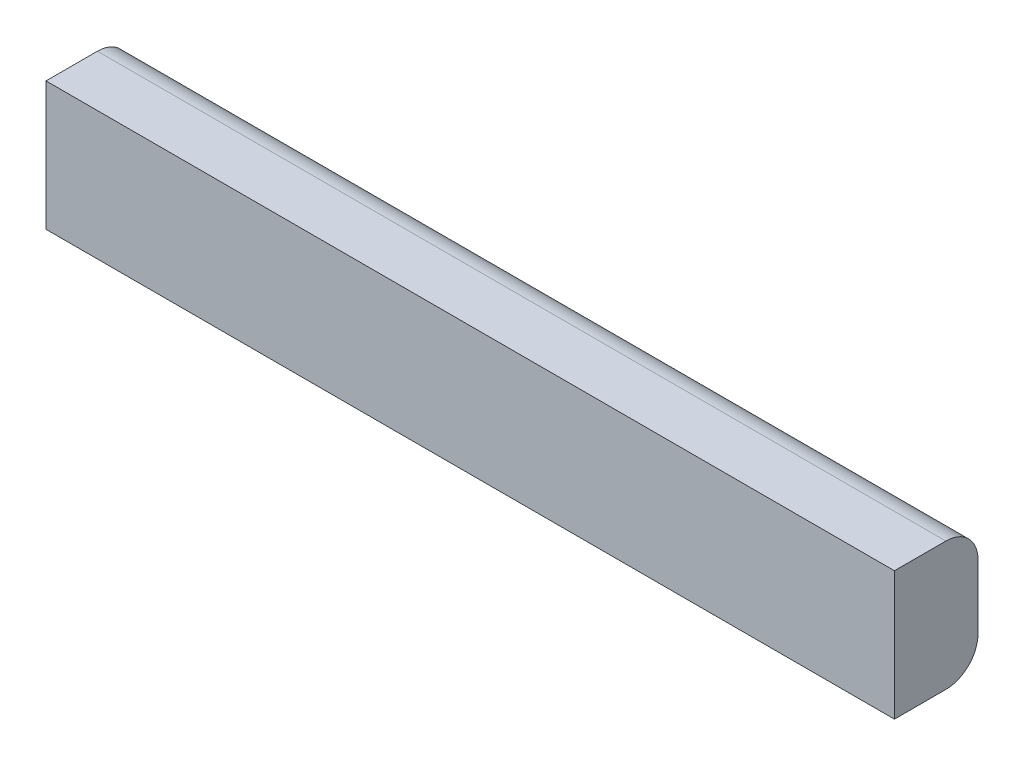
from build123d import *

# Parameters (mm, degrees)
BOSS_EXTRUDE1_DEPTH = 419.1


with BuildPart() as part:
    # Sketch1 → Boss-Extrude1 (new body, symmetric)
    with BuildSketch(Plane(origin=(0, 0, 0), x_dir=(0, 0, -1), z_dir=(1, 0, 0))):
        with BuildLine():
            Line((49.373646209, 66.02166065), (-1.426353791, 66.02166065))
            Line((-1.426353791, 66.02166065), (-1.426353791, -60.97833935))
            Line((-1.426353791, -60.97833935), (49.373646209, -60.97833935))
            ThreePointArc((49.373646209, -60.97833935), (71.824286512, -51.678979653), (81.123646209, -29.22833935))
            Line((81.123646209, -29.22833935), (81.123646209, 34.27166065))
            ThreePointArc((81.123646209, 34.27166065), (71.824286512, 56.722300952), (49.373646209, 66.02166065))
        make_face()
    extrude(amount=BOSS_EXTRUDE1_DEPTH, both=True)


solid = part.part
